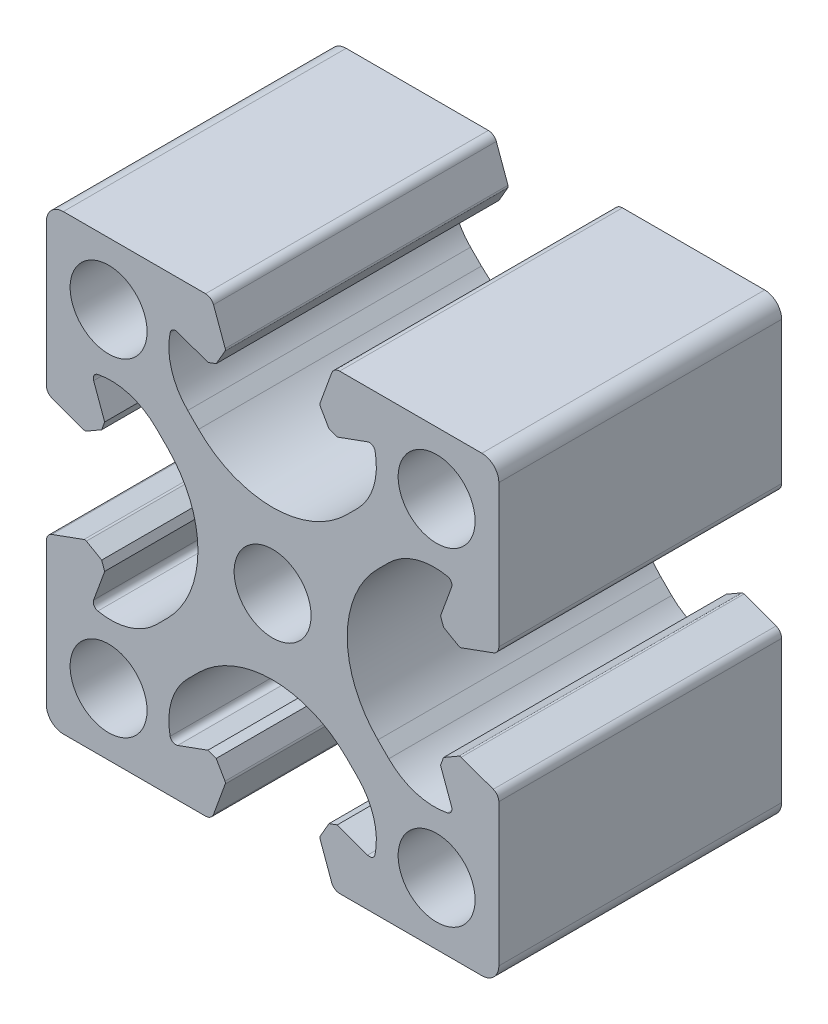
from build123d import *

# Parameters (mm, degrees)
SK_MAIN_EXTRUSION_R  = 3.4
MAIN_EXTRUSION_DEPTH = 25


with BuildPart() as part:
    # Sk Main Extrusion → Main Extrusion (new body)
    with BuildSketch(Plane.XY):
        with BuildLine():
            Line((4.190076845, -16.671180212), (5.222054351, -19.506515107))
            ThreePointArc((5.222054351, -19.506515107), (5.496641489, -19.864364033), (5.926823816, -20))
            Line((5.926823816, -20), (18.5, -20))
            ThreePointArc((18.5, -20), (19.560660172, -19.560660172), (20, -18.5))
            Line((20, -18.5), (20, -5.926823816))
            ThreePointArc((20, -5.926823816), (19.864364033, -5.496641489), (19.506515107, -5.222054351))
            Line((19.506515107, -5.222054351), (16.671180212, -4.190076845))
            ThreePointArc((16.671180212, -4.190076845), (16.563886241, -4.175951325), (16.460675177, -4.208493649))
            Line((16.460675177, -4.208493649), (15.111296024, -4.987558066))
            Line((15.111296024, -4.987558066), (14.845251581, -5.718509166))
            Line((14.845251581, -5.718509166), (15.81984631, -8.396186179))
            ThreePointArc((15.81984631, -8.396186179), (15.786489799, -8.811074612), (15.450654467, -9.056960151))
            ThreePointArc((15.450654467, -9.056960151), (12.665882372, -8.933433013), (10.272684887, -7.504160339))
            Line((10.272684887, -7.504160339), (9.309262274, -6.540737726))
            ThreePointArc((9.309262274, -6.540737726), (6.6, 0), (9.309262274, 6.540737726))
            Line((9.309262274, 6.540737726), (10.272684887, 7.504160339))
            ThreePointArc((10.272684887, 7.504160339), (12.665882372, 8.933433013), (15.450654467, 9.056960151))
            ThreePointArc((15.450654467, 9.056960151), (15.786489799, 8.811074612), (15.81984631, 8.396186179))
            Line((15.81984631, 8.396186179), (14.845251581, 5.718509166))
            Line((14.845251581, 5.718509166), (15.111296024, 4.987558066))
            Line((15.111296024, 4.987558066), (16.460675177, 4.208493649))
            ThreePointArc((16.460675177, 4.208493649), (16.563886241, 4.175951325), (16.671180212, 4.190076845))
            Line((16.671180212, 4.190076845), (19.506515107, 5.222054351))
            ThreePointArc((19.506515107, 5.222054351), (19.864364033, 5.496641489), (20, 5.926823816))
            Line((20, 5.926823816), (20, 18.5))
            ThreePointArc((20, 18.5), (19.560660172, 19.560660172), (18.5, 20))
            Line((18.5, 20), (5.926823816, 20))
            ThreePointArc((5.926823816, 20), (5.496641489, 19.864364033), (5.222054351, 19.506515107))
            Line((5.222054351, 19.506515107), (4.190076845, 16.671180212))
            ThreePointArc((4.190076845, 16.671180212), (4.175951325, 16.563886241), (4.208493649, 16.460675177))
            Line((4.208493649, 16.460675177), (4.987558066, 15.111296024))
            Line((4.987558066, 15.111296024), (5.718509166, 14.845251581))
            Line((5.718509166, 14.845251581), (8.396186179, 15.81984631))
            ThreePointArc((8.396186179, 15.81984631), (8.811074612, 15.786489799), (9.056960151, 15.450654467))
            ThreePointArc((9.056960151, 15.450654467), (8.933433013, 12.665882372), (7.504160339, 10.272684887))
            Line((7.504160339, 10.272684887), (6.540737726, 9.309262274))
            ThreePointArc((6.540737726, 9.309262274), (0, 6.6), (-6.540737726, 9.309262274))
            Line((-6.540737726, 9.309262274), (-7.504160339, 10.272684887))
            ThreePointArc((-7.504160339, 10.272684887), (-8.933433013, 12.665882372), (-9.056960151, 15.450654467))
            ThreePointArc((-9.056960151, 15.450654467), (-8.811074612, 15.786489799), (-8.396186179, 15.81984631))
            Line((-8.396186179, 15.81984631), (-5.718509166, 14.845251581))
            Line((-5.718509166, 14.845251581), (-4.987558066, 15.111296024))
            Line((-4.987558066, 15.111296024), (-4.208493649, 16.460675177))
            ThreePointArc((-4.208493649, 16.460675177), (-4.175951325, 16.563886241), (-4.190076845, 16.671180212))
            Line((-4.190076845, 16.671180212), (-5.222054351, 19.506515107))
            ThreePointArc((-5.222054351, 19.506515107), (-5.496641489, 19.864364033), (-5.926823816, 20))
            Line((-5.926823816, 20), (-18.5, 20))
            ThreePointArc((-18.5, 20), (-19.560660172, 19.560660172), (-20, 18.5))
            Line((-20, 18.5), (-20, 5.926823816))
            ThreePointArc((-20, 5.926823816), (-19.864364033, 5.496641489), (-19.506515107, 5.222054351))
            Line((-19.506515107, 5.222054351), (-16.671180212, 4.190076845))
            ThreePointArc((-16.671180212, 4.190076845), (-16.563886241, 4.175951325), (-16.460675177, 4.208493649))
            Line((-16.460675177, 4.208493649), (-15.111296024, 4.987558066))
            Line((-15.111296024, 4.987558066), (-14.845251581, 5.718509166))
            Line((-14.845251581, 5.718509166), (-15.81984631, 8.396186179))
            ThreePointArc((-15.81984631, 8.396186179), (-15.786489799, 8.811074612), (-15.450654467, 9.056960151))
            ThreePointArc((-15.450654467, 9.056960151), (-12.665882372, 8.933433013), (-10.272684887, 7.504160339))
            Line((-10.272684887, 7.504160339), (-9.309262274, 6.540737726))
            ThreePointArc((-9.309262274, 6.540737726), (-6.6, 0), (-9.309262274, -6.540737726))
            Line((-9.309262274, -6.540737726), (-10.272684887, -7.504160339))
            ThreePointArc((-10.272684887, -7.504160339), (-12.665882372, -8.933433013), (-15.450654467, -9.056960151))
            ThreePointArc((-15.450654467, -9.056960151), (-15.786489799, -8.811074612), (-15.81984631, -8.396186179))
            Line((-15.81984631, -8.396186179), (-14.845251581, -5.718509166))
            Line((-14.845251581, -5.718509166), (-15.111296024, -4.987558066))
            Line((-15.111296024, -4.987558066), (-16.460675177, -4.208493649))
            ThreePointArc((-16.460675177, -4.208493649), (-16.563886241, -4.175951325), (-16.671180212, -4.190076845))
            Line((-16.671180212, -4.190076845), (-19.506515107, -5.222054351))
            ThreePointArc((-19.506515107, -5.222054351), (-19.864364033, -5.496641489), (-20, -5.926823816))
            Line((-20, -5.926823816), (-20, -18.5))
            ThreePointArc((-20, -18.5), (-19.560660172, -19.560660172), (-18.5, -20))
            Line((-18.5, -20), (-5.926823816, -20))
            ThreePointArc((-5.926823816, -20), (-5.496641489, -19.864364033), (-5.222054351, -19.506515107))
            Line((-5.222054351, -19.506515107), (-4.190076845, -16.671180212))
            ThreePointArc((-4.190076845, -16.671180212), (-4.175951325, -16.563886241), (-4.208493649, -16.460675177))
            Line((-4.208493649, -16.460675177), (-4.987558066, -15.111296024))
            Line((-4.987558066, -15.111296024), (-5.718509166, -14.845251581))
            Line((-5.718509166, -14.845251581), (-8.396186179, -15.81984631))
            ThreePointArc((-8.396186179, -15.81984631), (-8.811074612, -15.786489799), (-9.056960151, -15.450654467))
            ThreePointArc((-9.056960151, -15.450654467), (-8.933433013, -12.665882372), (-7.504160339, -10.272684887))
            Line((-7.504160339, -10.272684887), (-6.540737726, -9.309262274))
            ThreePointArc((-6.540737726, -9.309262274), (0, -6.6), (6.540737726, -9.309262274))
            Line((6.540737726, -9.309262274), (7.504160339, -10.272684887))
            ThreePointArc((7.504160339, -10.272684887), (8.933433013, -12.665882372), (9.056960151, -15.450654467))
            ThreePointArc((9.056960151, -15.450654467), (8.811074612, -15.786489799), (8.396186179, -15.81984631))
            Line((8.396186179, -15.81984631), (5.718509166, -14.845251581))
            Line((5.718509166, -14.845251581), (4.987558066, -15.111296024))
            Line((4.987558066, -15.111296024), (4.208493649, -16.460675177))
            ThreePointArc((4.208493649, -16.460675177), (4.175951325, -16.563886241), (4.190076845, -16.671180212))
        make_face()
        with Locations((-14.5, -14.5)):
            Circle(SK_MAIN_EXTRUSION_R, mode=Mode.SUBTRACT)
        with Locations((14.5, -14.5)):
            Circle(SK_MAIN_EXTRUSION_R, mode=Mode.SUBTRACT)
        with Locations((14.5, 14.5)):
            Circle(SK_MAIN_EXTRUSION_R, mode=Mode.SUBTRACT)
        with Locations((-14.5, 14.5)):
            Circle(SK_MAIN_EXTRUSION_R, mode=Mode.SUBTRACT)
        Circle(SK_MAIN_EXTRUSION_R, mode=Mode.SUBTRACT)
    extrude(amount=-MAIN_EXTRUSION_DEPTH)


solid = part.part
